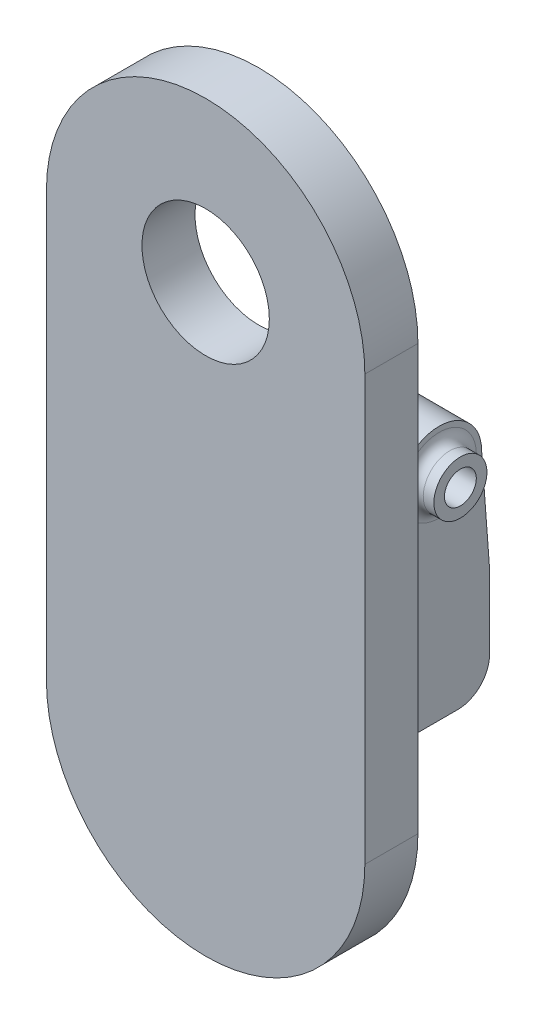
from build123d import *

# Parameters (mm, degrees)
SKETCH1_R           = 6
BOSS_EXTRUDE1_DEPTH = 5
SKETCH2_W           = 5
SKETCH2_H           = 10
BOSS_EXTRUDE2_DEPTH = 25
SKETCH3_R           = 1.5
BOSS_EXTRUDE3_DEPTH = 5
BOSS_EXTRUDE4_DEPTH = 8
BOSS_EXTRUDE5_REACH = 66.735
SKETCH5_R           = 1.5
SKETCH6_R           = 2.5
SKETCH6_R_2         = 1.5
BOSS_EXTRUDE6_DEPTH = 2
FILLET1_R           = 1
FILLET2_R           = 3


with BuildPart() as part:
    # Sketch1 → Boss-Extrude1 (new body)
    with BuildSketch(Plane.XY):
        with BuildLine():
            Line((15, 0), (15, -40))
            ThreePointArc((15, -40), (0, -55), (-15, -40))
            Line((-15, -40), (-15, 0))
            ThreePointArc((-15, 0), (0, 15), (15, 0))
        make_face()
        Circle(SKETCH1_R, mode=Mode.SUBTRACT)
    extrude(amount=BOSS_EXTRUDE1_DEPTH)

    # Sketch2 → Boss-Extrude2 (add)
    with BuildSketch(Plane(origin=(0, 0, 0), x_dir=(-1, 0, 0), z_dir=(0, 0, -1))):
        with Locations((5.75, -45)):
            Rectangle(SKETCH2_W, SKETCH2_H)
    extrude(amount=BOSS_EXTRUDE2_DEPTH)

    # Sketch3 → Boss-Extrude3 (add)
    with BuildSketch(Plane(origin=(-3.25, 0, 0), x_dir=(0, 0, -1), z_dir=(1, 0, 0))):
        with BuildLine():
            Line((24.25, -30), (25, -40))
            Line((25, -40), (15.5, -40))
            Line((15.5, -40), (16.25, -30))
            ThreePointArc((16.25, -30), (20.25, -26), (24.25, -30))
        make_face()
        with Locations(Location((20.25, -30, 0), (0, 0, 90))):
            Circle(SKETCH3_R, mode=Mode.SUBTRACT)
    extrude(amount=-BOSS_EXTRUDE3_DEPTH)

    # Sketch4 → Boss-Extrude4 (add)
    with BuildSketch(Plane.XZ.offset(50)):
        Polygon((-8.25, -25), (-8.25, 0), (-10.25, 0), align=None)
    extrude(amount=-BOSS_EXTRUDE4_DEPTH)

    # Boss-Extrude5: up to this face of the body (flat: up to its plane)
    boss_extrude5_end = Plane(part.part.faces().sort_by_distance((-9.25, -46, -12.5))[0])
    # Sketch5 → Boss-Extrude5 (add, up to the picked face)
    with BuildSketch(Plane.ZY.offset(8.25), mode=Mode.PRIVATE) as boss_extrude5_sk1:
        with BuildLine():
            Line((-24.25, -30), (-25, -40))
            Line((-25, -40), (-25, -42))
            Line((-25, -42), (0, -42))
            Line((0, -42), (0, -40))
            Line((0, -40), (-15.5, -40))
            Line((-15.5, -40), (-16.25, -30))
            ThreePointArc((-16.25, -30), (-20.25, -26), (-24.25, -30))
        make_face()
        with Locations(Location((-20.25, -30, 0), (0, 0, 90))):
            Circle(SKETCH5_R, mode=Mode.SUBTRACT)
    boss_extrude5_tool1 = split(extrude(boss_extrude5_sk1.sketch, amount=BOSS_EXTRUDE5_REACH, mode=Mode.PRIVATE), bisect_by=boss_extrude5_end, keep=Keep.BOTH, mode=Mode.PRIVATE)
    add(boss_extrude5_tool1.solids().sort_by(Axis((-8.25, -36.153945, -17.759066), (-1, 0, 0)))[0])

    # Sketch6 → Boss-Extrude6 (add)
    with BuildSketch(Plane(origin=(-3.25, 0, 0), x_dir=(0, 0, -1), z_dir=(1, 0, 0))):
        with Locations(Location((20.25, -30, 0), (0, 0, 270))):
            Circle(SKETCH6_R)
        with Locations(Location((20.25, -30, 0), (0, 0, 90))):
            Circle(SKETCH6_R_2, mode=Mode.SUBTRACT)
    extrude(amount=BOSS_EXTRUDE6_DEPTH)

    # Fillet1
    fillet1_edges = [part.edges().sort_by_distance(p)[0] for p in [
        (-3.25, -27.5, -20.25),
    ]]
    fillet(fillet1_edges, radius=FILLET1_R)

    # Fillet2
    fillet2_edges = [part.edges().sort_by_distance(p)[0] for p in [
        (-5.75, -50, -25),
        (-6.13, -40, -15.5),
    ]]
    fillet(fillet2_edges, radius=FILLET2_R)


solid = part.part
